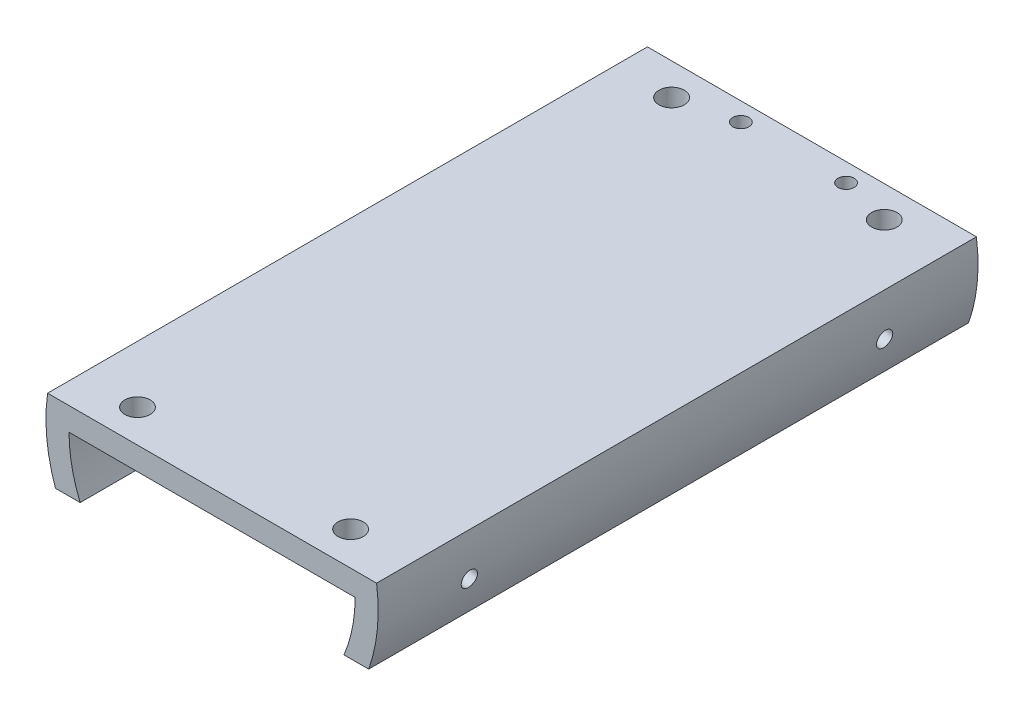
from build123d import *

# Parameters (mm, degrees)
BOSS_EXTRUDE1_DEPTH     = 65
CUT_EXTRUDE1_REACH      = 70.199
SKETCH2_R               = 1.374999977
SKETCH2_R_2             = 1.374999979
SKETCH2_R_3             = 1.374999935
SKETCH2_R_4             = 1.374999972
BOSS_EXTRUDE2_DEPTH     = 65
CUT_EXTRUDE3_REACH      = 70.199
CUT_EXTRUDE3_END_RADIUS = 9
SKETCH5_R               = 0.875
CUT_EXTRUDE4_REACH      = 76.384
CUT_EXTRUDE4_END_RADIUS = 15.5
SKETCH6_R               = 0.875
BOSS_EXTRUDE3_DEPTH     = 26
CUT_EXTRUDE7_DEPTH      = 69
SKETCH11_W              = 28.583211856
SKETCH11_H              = 6.5
CUT_EXTRUDE8_DEPTH      = 69


with BuildPart() as part:
    # Sketch1 → Boss-Extrude1 (new body)
    with BuildSketch(Plane.XY):
        with BuildLine():
            ThreePointArc((16.313540167, -7.607128711), (17.573328128, -3.895913051), (18, 0))
            Line((18, 0), (15.5, 0))
            ThreePointArc((15.5, 0), (15.13258811, -3.354814016), (14.047770699, -6.550583057))
            Line((14.047770699, -6.550583057), (16.313540167, -7.607128711))
        make_face()
        with BuildLine():
            Line((15.5, 0), (18, 0))
            ThreePointArc((18, 0), (17.9563329, 1.253039812), (17.82554347, 2.5))
            Line((17.82554347, 2.5), (15.297058541, 2.5))
            ThreePointArc((15.297058541, 2.5), (15.449181328, 1.254111761), (15.5, 0))
        make_face()
        with BuildLine():
            Line((-15.297058541, 2.5), (-17.82554347, 2.5))
            ThreePointArc((-17.82554347, 2.5), (-17.9563329, 1.253039812), (-18, 0))
            Line((-18, 0), (-15.5, 0))
            ThreePointArc((-15.5, 0), (-15.449181328, 1.254111761), (-15.297058541, 2.5))
        make_face()
        with BuildLine():
            Line((0, 0), (15.5, 0))
            ThreePointArc((15.5, 0), (15.449181328, 1.254111761), (15.297058541, 2.5))
            Line((15.297058541, 2.5), (-15.297058541, 2.5))
            ThreePointArc((-15.297058541, 2.5), (-15.449181328, 1.254111761), (-15.5, 0))
            Line((-15.5, 0), (0, 0))
        make_face()
        with BuildLine():
            ThreePointArc((-18, 0), (-17.573328128, -3.895913051), (-16.313540167, -7.607128711))
            Line((-16.313540167, -7.607128711), (-14.047770699, -6.550583057))
            ThreePointArc((-14.047770699, -6.550583057), (-15.13258811, -3.354814016), (-15.5, 0))
            Line((-15.5, 0), (-18, 0))
        make_face()
        with BuildLine():
            Line((15.5, 0), (18, 0))
            ThreePointArc((18, 0), (17.9563329, 1.253039812), (17.82554347, 2.5))
            Line((17.82554347, 2.5), (15.297058541, 2.5))
            ThreePointArc((15.297058541, 2.5), (15.449181328, 1.254111761), (15.5, 0))
        make_face()
        with BuildLine():
            Line((-15.297058541, 2.5), (-17.82554347, 2.5))
            ThreePointArc((-17.82554347, 2.5), (-17.9563329, 1.253039812), (-18, 0))
            Line((-18, 0), (-15.5, 0))
            ThreePointArc((-15.5, 0), (-15.449181328, 1.254111761), (-15.297058541, 2.5))
        make_face()
    extrude(amount=BOSS_EXTRUDE1_DEPTH)

    # Sketch2 → Cut-Extrude1 (cut, up to next)
    with BuildSketch(Plane(origin=(0, 2.5, 0), x_dir=(1, 0, 0), z_dir=(0, 1, 0)), mode=Mode.PRIVATE) as cut_extrude1_sk1:
        with Locations(Location((11.239474716, -3.394559676, 0), (0, 0, 270))):
            Circle(SKETCH2_R)
    cut_extrude1_tool1 = extrude(cut_extrude1_sk1.sketch, amount=-CUT_EXTRUDE1_REACH, mode=Mode.PRIVATE) & part.part
    # Sketch2 → Cut-Extrude1 (cut, up to next)
    with BuildSketch(Plane(origin=(0, 2.5, 0), x_dir=(1, 0, 0), z_dir=(0, 1, 0)), mode=Mode.PRIVATE) as cut_extrude1_sk2:
        with Locations(Location((-11.760472903, -3.443135131, 0), (0, 0, 270))):
            Circle(SKETCH2_R_2)
    cut_extrude1_tool2 = extrude(cut_extrude1_sk2.sketch, amount=-CUT_EXTRUDE1_REACH, mode=Mode.PRIVATE) & part.part
    # Sketch2 → Cut-Extrude1 (cut, up to next)
    with BuildSketch(Plane(origin=(0, 2.5, 0), x_dir=(1, 0, 0), z_dir=(0, 1, 0)), mode=Mode.PRIVATE) as cut_extrude1_sk3:
        with Locations(Location((11.361823253, -61.347443071, 0), (0, 0, 270))):
            Circle(SKETCH2_R_3)
    cut_extrude1_tool3 = extrude(cut_extrude1_sk3.sketch, amount=-CUT_EXTRUDE1_REACH, mode=Mode.PRIVATE) & part.part
    # Sketch2 → Cut-Extrude1 (cut, up to next)
    with BuildSketch(Plane(origin=(0, 2.5, 0), x_dir=(1, 0, 0), z_dir=(0, 1, 0)), mode=Mode.PRIVATE) as cut_extrude1_sk4:
        with Locations(Location((-11.637978285, -61.443005778, 0), (0, 0, 270))):
            Circle(SKETCH2_R_4)
    cut_extrude1_tool4 = extrude(cut_extrude1_sk4.sketch, amount=-CUT_EXTRUDE1_REACH, mode=Mode.PRIVATE) & part.part
    add(cut_extrude1_tool1.solids().sort_by_distance((11.239475, 2.5, 3.39456))[0], mode=Mode.SUBTRACT)
    add(cut_extrude1_tool2.solids().sort_by_distance((-11.760473, 2.5, 3.443135))[0], mode=Mode.SUBTRACT)
    add(cut_extrude1_tool3.solids().sort_by_distance((11.361823, 2.5, 61.347443))[0], mode=Mode.SUBTRACT)
    add(cut_extrude1_tool4.solids().sort_by_distance((-11.637978, 2.5, 61.443006))[0], mode=Mode.SUBTRACT)

    # Sketch3 → Boss-Extrude2 (add)
    with BuildSketch(Plane.XY.offset(65)):
        with BuildLine():
            Line((-9, 0), (-9, -6))
            Line((-9, -6), (-8.485281374, -6))
            ThreePointArc((-8.485281374, -6), (-5.196152423, -1.651530772), (0, 0))
            Line((0, 0), (-9, 0))
        make_face()
        with BuildLine():
            ThreePointArc((0, 0), (5.196152423, -1.651530772), (8.485281374, -6))
            Line((8.485281374, -6), (9, -6))
            Line((9, -6), (9, 0))
            Line((9, 0), (0, 0))
        make_face()
    extrude(amount=-BOSS_EXTRUDE2_DEPTH)

    # Cut-Extrude3: up to this cylinder (the profile starts outside it)
    cut_extrude3_end = Plane(origin=(0, -9, 2), z_dir=(0, 0, 1)) * Cylinder(CUT_EXTRUDE3_END_RADIUS, 159.398, mode=Mode.PRIVATE)
    # Sketch5 → Cut-Extrude3 (cut, up to the surface)
    with BuildSketch(Plane(origin=(0, 2.5, 0), x_dir=(1, 0, 0), z_dir=(0, 1, 0)), mode=Mode.PRIVATE) as cut_extrude3_sk1:
        with Locations(Location((-5.7, -2, 0), (0, 0, 270))):
            Circle(SKETCH5_R)
    cut_extrude3_tool1 = extrude(cut_extrude3_sk1.sketch, amount=-CUT_EXTRUDE3_REACH, mode=Mode.PRIVATE) - cut_extrude3_end
    add(cut_extrude3_tool1.solids().sort_by_distance((-5.7, 2.5, 2))[0], mode=Mode.SUBTRACT)
    # Sketch5 → Cut-Extrude3 (cut, up to the surface)
    with BuildSketch(Plane(origin=(0, 2.5, 0), x_dir=(1, 0, 0), z_dir=(0, 1, 0)), mode=Mode.PRIVATE) as cut_extrude3_sk2:
        with Locations(Location((5.7, -2, 0), (0, 0, 270))):
            Circle(SKETCH5_R)
    cut_extrude3_tool2 = extrude(cut_extrude3_sk2.sketch, amount=-CUT_EXTRUDE3_REACH, mode=Mode.PRIVATE) - cut_extrude3_end
    add(cut_extrude3_tool2.solids().sort_by_distance((5.7, 2.5, 2))[0], mode=Mode.SUBTRACT)

    # Cut-Extrude4: up to this cylinder (the profile starts outside it)
    cut_extrude4_end = Plane(origin=(0, 0, 32.5), z_dir=(0, 0, -1)) * Cylinder(CUT_EXTRUDE4_END_RADIUS, 229.768, mode=Mode.PRIVATE)
    # Sketch6 → Cut-Extrude4 (cut, up to the surface)
    with BuildSketch(Plane(origin=(-17.726539554, -3.125667198, 0), x_dir=(0, 0, -1), z_dir=(-0.984807753012208, -0.17364817766693072, 0)), mode=Mode.PRIVATE) as cut_extrude4_sk1:
        with Locations(Location((-55, -1.057392522, 0), (0, 0, 90))):
            Circle(SKETCH6_R)
    cut_extrude4_tool1 = extrude(cut_extrude4_sk1.sketch, amount=-CUT_EXTRUDE4_REACH, mode=Mode.PRIVATE) - cut_extrude4_end
    # Sketch6 → Cut-Extrude4 (cut, up to the surface)
    with BuildSketch(Plane(origin=(-17.726539554, -3.125667198, 0), x_dir=(0, 0, -1), z_dir=(-0.984807753012208, -0.17364817766693072, 0)), mode=Mode.PRIVATE) as cut_extrude4_sk2:
        with Locations(Location((-10, -1.057392522, 0), (0, 0, 90))):
            Circle(SKETCH6_R)
    cut_extrude4_tool2 = extrude(cut_extrude4_sk2.sketch, amount=-CUT_EXTRUDE4_REACH, mode=Mode.PRIVATE) - cut_extrude4_end
    cut_extrude4 = cut_extrude4_tool1.solids().sort_by_distance((-17.910154, -2.084339, 55))[0] + cut_extrude4_tool2.solids().sort_by_distance((-17.910154, -2.084339, 10))[0]
    add(cut_extrude4, mode=Mode.SUBTRACT)

    # Mirror1: Cut-Extrude4 across plane
    add(cut_extrude4.mirror(Plane(origin=(0, 0, 0), x_dir=(0, 0, 1), z_dir=(1, 0, 0))), mode=Mode.SUBTRACT)

    # Sketch8 → Boss-Extrude3 (add, symmetric)
    with BuildSketch(Plane.XY.offset(32.5)):
        with BuildLine():
            Line((-14.291605928, -6), (-9, -6))
            Line((-9, -6), (-9, 0))
            Line((-9, 0), (-15.5, 0))
            ThreePointArc((-15.5, 0), (-15.194898682, -3.060237582), (-14.291605928, -6))
        make_face()
        with BuildLine():
            Line((9, 0), (9, -6))
            Line((9, -6), (14.291605928, -6))
            ThreePointArc((14.291605928, -6), (15.194898682, -3.060237582), (15.5, 0))
            Line((15.5, 0), (9, 0))
        make_face()
    extrude(amount=BOSS_EXTRUDE3_DEPTH, both=True)

    # Sketch9 → Cut-Extrude7 (cut)
    with BuildSketch(Plane.XY.offset(65)):
        with BuildLine():
            ThreePointArc((-14.047770699, -6.550583057), (-14.172362271, -6.276475737), (-14.291605928, -6))
            Line((-14.291605928, -6), (-16.970562748, -6))
            ThreePointArc((-16.970562748, -6), (-16.661440286, -6.811490851), (-16.313540167, -7.607128711))
            Line((-16.313540167, -7.607128711), (-14.047770699, -6.550583057))
        make_face()
        with BuildLine():
            Line((16.970562748, -6), (14.291605928, -6))
            ThreePointArc((14.291605928, -6), (14.172362271, -6.276475737), (14.047770699, -6.550583057))
            Line((14.047770699, -6.550583057), (16.313540167, -7.607128711))
            ThreePointArc((16.313540167, -7.607128711), (16.661440286, -6.811490851), (16.970562748, -6))
        make_face()
    extrude(amount=-CUT_EXTRUDE7_DEPTH, mode=Mode.SUBTRACT)

    # Sketch11 → Cut-Extrude8 (cut)
    with BuildSketch(Plane(origin=(0, 0, 0), x_dir=(-1, 0, 0), z_dir=(0, -1, 0))):
        with Locations((0, -61.75)):
            Rectangle(SKETCH11_W, SKETCH11_H)
        with Locations((0, -3.25)):
            Rectangle(SKETCH11_W, SKETCH11_H)
    extrude(amount=CUT_EXTRUDE8_DEPTH, mode=Mode.SUBTRACT)


solid = part.part
